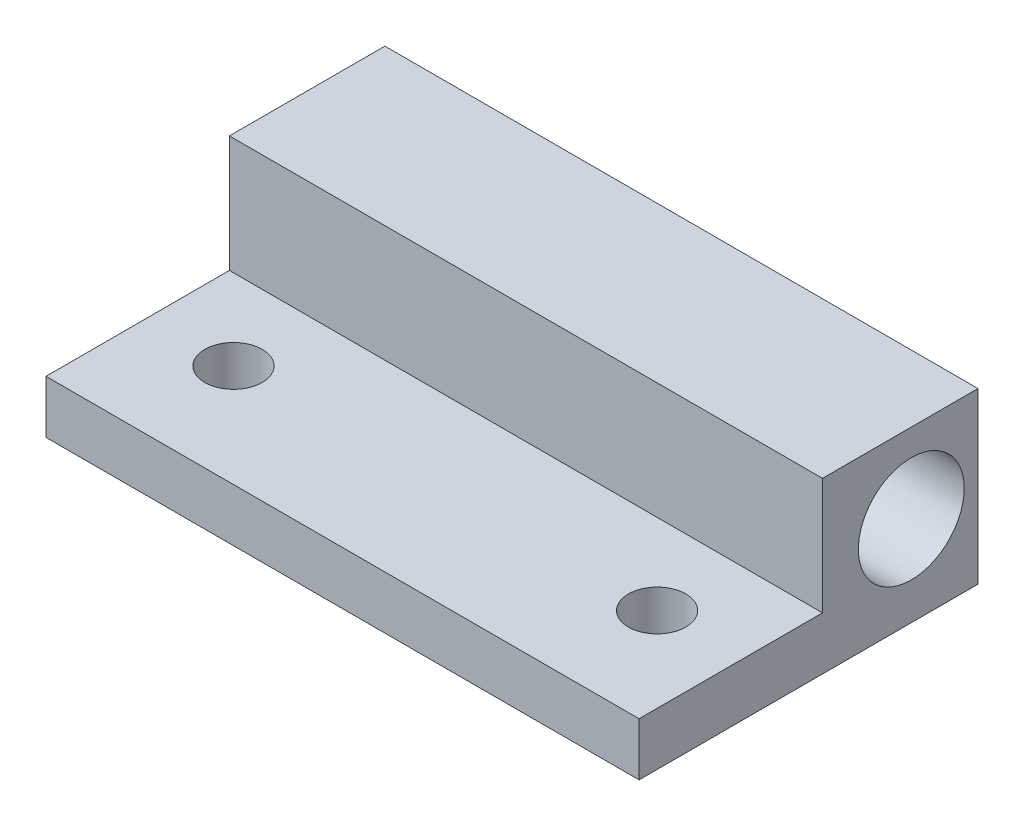
from build123d import *

# Parameters (mm, degrees)
SKETCH1_W                        = 44.45
SKETCH1_H                        = 25.4
BOSS_EXTRUDE1_DEPTH              = 12.7
CUT_EXTRUDE1_REACH               = 46.45
SKETCH2_R                        = 3.96875
F_18_0_1695_DIAMETER_HOLE1_D     = 4.3053
F_18_0_1695_DIAMETER_HOLE1_DEPTH = 12.7
SKETCH5_W                        = 44.45
SKETCH5_H                        = 13.74547341
CUT_EXTRUDE2_DEPTH               = 8.73125


with BuildPart() as part:
    # Sketch1 → Boss-Extrude1 (new body)
    with BuildSketch(Plane(origin=(0, 0, 0), x_dir=(1, 0, 0), z_dir=(0, 1, 0))):
        with Locations((-34.470243637, -32.242582921)):
            Rectangle(SKETCH1_W, SKETCH1_H)
    extrude(amount=BOSS_EXTRUDE1_DEPTH)

    # Sketch2 → Cut-Extrude1 (cut, up to next)
    with BuildSketch(Plane(origin=(-12.245243637, 0, 0), x_dir=(0, 0, -1), z_dir=(1, 0, 0)), mode=Mode.PRIVATE) as cut_extrude1_sk1:
        with Locations((-24.543510458, 6.746875)):
            Circle(SKETCH2_R)
    cut_extrude1_tool1 = extrude(cut_extrude1_sk1.sketch, amount=-CUT_EXTRUDE1_REACH, mode=Mode.PRIVATE) & part.part
    add(cut_extrude1_tool1.solids().sort_by_distance((-12.245244, 6.746875, 24.54351))[0], mode=Mode.SUBTRACT)

    # #18 (0.1695) Diameter Hole1
    with Locations(Plane(origin=(0, 12.7, 0), x_dir=(-1, 0, 0), z_dir=(0, 1, 0))):
        with Locations((50.345243637, 37.243510458), (18.595243637, 37.243510458)):
            Hole(F_18_0_1695_DIAMETER_HOLE1_D / 2, depth=F_18_0_1695_DIAMETER_HOLE1_DEPTH)

    # Sketch5 → Cut-Extrude2 (cut)
    with BuildSketch(Plane(origin=(0, 12.7, 0), x_dir=(1, 0, 0), z_dir=(0, 1, 0))):
        with Locations((-34.470243637, -38.069846216)):
            Rectangle(SKETCH5_W, SKETCH5_H)
    extrude(amount=-CUT_EXTRUDE2_DEPTH, mode=Mode.SUBTRACT)


solid = part.part
